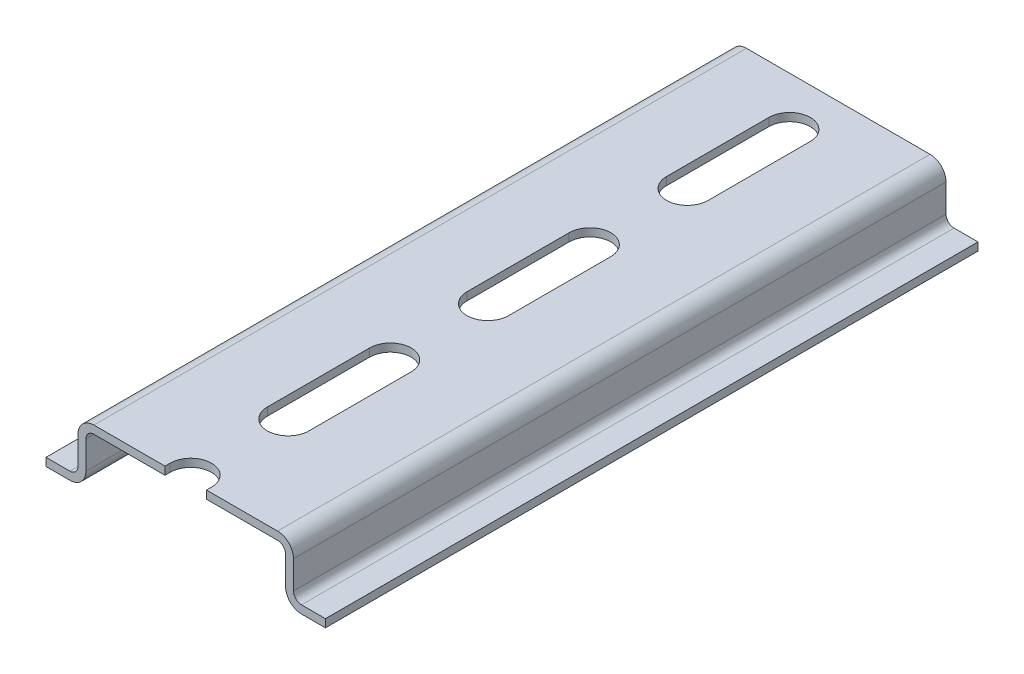
from build123d import *

# Parameters (mm, degrees)
LIN_AUSTRAG_D_NN_GK_START = -22.647765
LIN_AUSTRAG_D_NN_GK_DEPTH = 81.730586
SCHNITT_LIN_LALO_DEPTH    = 8.5
LIN_MUSTER_LALO_COUNT     = 4
LIN_MUSTER_LALO_PITCH     = 25
VERRUNDG_BIEGUNG_R        = 1
VERRUNDG_BIEGUNG_2_R      = 2


with BuildPart() as part:
    # Profil → Lin-Austrag-D_nn_GK (new body)
    with BuildSketch(Plane.XY.offset(LIN_AUSTRAG_D_NN_GK_START)):
        Polygon((-17.5, -6.5), (-13.5, -6.5), (-13.5, 0), (13.5, 0), (13.5, -6.5), (17.5, -6.5), (17.5, -7.5), (12.5, -7.5), (12.5, -1), (-12.5, -1), (-12.5, -7.5), (-17.5, -7.5), align=None)
    extrude(amount=LIN_AUSTRAG_D_NN_GK_DEPTH)

    # LaLo → Schnitt-Lin_LaLo (cut, through all)
    with BuildSketch(Plane(origin=(0, 0, 0), x_dir=(1, 0, 0), z_dir=(0, 1, 0))):
        with BuildLine():
            Line((2.6, 16.547765182), (2.6, 3.747765182))
            ThreePointArc((2.6, 3.747765182), (0, 1.147765182), (-2.6, 3.747765182))
            Line((-2.6, 3.747765182), (-2.6, 16.547765182))
            ThreePointArc((-2.6, 16.547765182), (0, 19.147765182), (2.6, 16.547765182))
        make_face()
    schnitt_lin_lalo = extrude(amount=-SCHNITT_LIN_LALO_DEPTH, mode=Mode.SUBTRACT)

    # Lin Muster_LaLo: Schnitt-Lin_LaLo ×4
    with Locations(*[(0, 0, i * LIN_MUSTER_LALO_PITCH) for i in range(1, LIN_MUSTER_LALO_COUNT)]):
        add(schnitt_lin_lalo, mode=Mode.SUBTRACT)

    # Verrundg_Biegung
    verrundg_biegung_edges = [part.edges().sort_by_distance(p)[0] for p in [
        (-12.5, -1, 18.217528),
        (12.5, -1, 18.217528),
        (-13.5, -6.5, 18.217528),
        (13.5, -6.5, 18.217528),
    ]]
    fillet(verrundg_biegung_edges, radius=VERRUNDG_BIEGUNG_R)

    # Verrundg_Biegung 2
    verrundg_biegung_2_edges = [part.edges().sort_by_distance(p)[0] for p in [
        (-13.5, 0, 18.217528),
        (13.5, 0, 18.217528),
        (-12.5, -7.5, 18.217528),
        (12.5, -7.5, 18.217528),
    ]]
    fillet(verrundg_biegung_2_edges, radius=VERRUNDG_BIEGUNG_2_R)


solid = part.part
